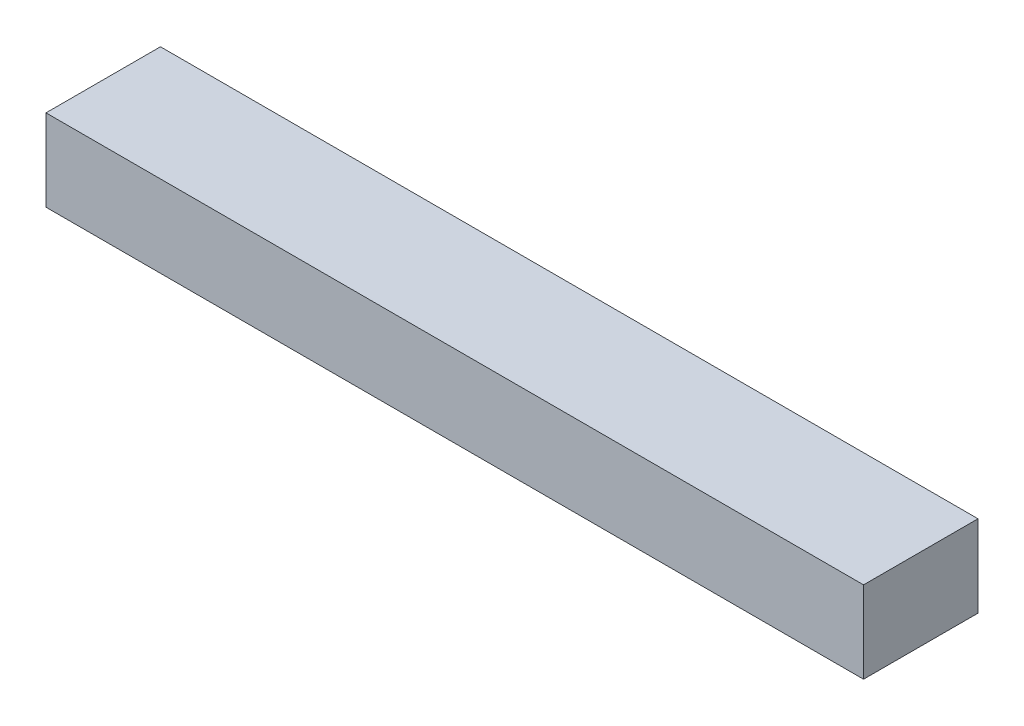
from build123d import *

# Parameters (mm, degrees)
SKETCH1_W           = 10
SKETCH1_H           = 1
BOSS_EXTRUDE1_DEPTH = 2
MOVE_FACE1_BY       = 0.3
MOVE_FACE2_BY       = 0.3


with BuildPart() as part:
    # Sketch1 → Boss-Extrude1 (new body)
    with BuildSketch(Plane.XY):
        Rectangle(SKETCH1_W, SKETCH1_H)
    extrude(amount=BOSS_EXTRUDE1_DEPTH)

    # Move Face1: a face moved inward by 0.3
    extrude(part.faces().sort_by_distance((0, 0, 0))[0], amount=MOVE_FACE1_BY, dir=(0, 0, 1), mode=Mode.SUBTRACT)

    # Move Face2: a face moved inward by 0.3
    extrude(part.faces().sort_by_distance((0, 0, 2))[0], amount=MOVE_FACE2_BY, dir=(0, 0, -1), mode=Mode.SUBTRACT)


solid = part.part
